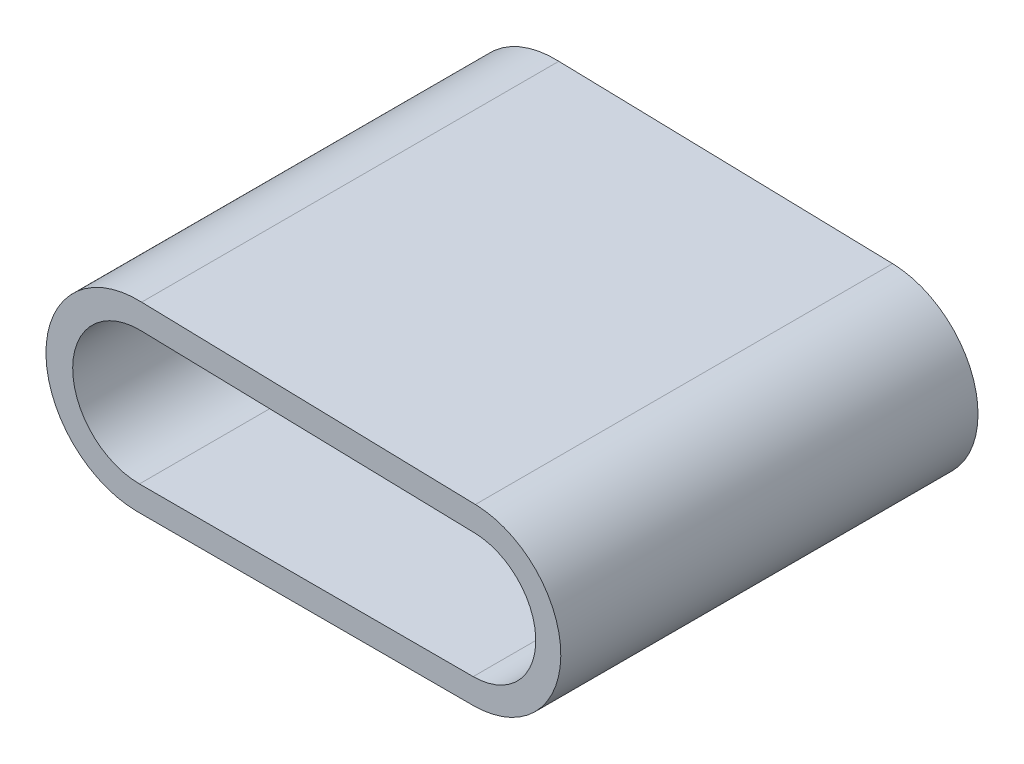
from build123d import *

# Parameters (mm, degrees)
SKETCH1_W           = 31.75
SKETCH1_H           = 31.75
BOSS_EXTRUDE1_DEPTH = 2.54
BOSS_EXTRUDE2_DEPTH = 31.75
CUT_EXTRUDE1_DEPTH  = 42.009788671


with BuildPart() as part:
    # Sketch1 → Boss-Extrude1 (new body)
    with BuildSketch(Plane(origin=(0, 0, 0), x_dir=(1, 0, 0), z_dir=(0, 1, 0))):
        Rectangle(SKETCH1_W, SKETCH1_H)
    extrude(amount=BOSS_EXTRUDE1_DEPTH)

    # Sketch2 → Boss-Extrude2 (add, through all)
    with BuildSketch(Plane.XY.offset(15.875)):
        with BuildLine():
            ThreePointArc((10.757698592, 11.42851198), (15.254678119, 7.83956856), (13.014608296, 2.54))
            Line((13.014608296, 2.54), (15.875, 2.54))
            ThreePointArc((15.875, 2.54), (16.673544098, 9.502227526), (10.805315687, 13.332916772))
            Line((10.805315687, 13.332916772), (-14.594684313, 13.9680098))
            ThreePointArc((-14.594684313, 13.9680098), (-21.844382089, 7.62745208), (-15.875, 0.069193847))
            Line((-15.875, 0.069193847), (-15.875, 2.028572795))
            ThreePointArc((-15.875, 2.028572795), (-19.803445065, 7.604369283), (-14.642301408, 12.063605008))
            Line((-14.642301408, 12.063605008), (10.757698592, 11.42851198))
        make_face()
        with BuildLine():
            ThreePointArc((13.014608296, 2.54), (11.868328068, 2.066487883), (10.638655855, 1.905))
            Line((10.638655855, 1.905), (-14.761344145, 1.905))
            ThreePointArc((-14.761344145, 1.905), (-15.321589537, 1.93598771), (-15.875, 2.028572795))
            Line((-15.875, 2.028572795), (-15.875, 0.069193847))
            ThreePointArc((-15.875, 0.069193847), (-15.444137647, 0.021191286), (-15.011127782, 0))
            Line((-15.011127782, 0), (-14.761344145, 0))
            Line((-14.761344145, 0), (10.638655855, 0))
            ThreePointArc((10.638655855, 0), (13.548591422, 0.668514148), (15.875, 2.54))
            Line((15.875, 2.54), (13.014608296, 2.54))
        make_face()
    extrude(amount=-BOSS_EXTRUDE2_DEPTH)

    # Sketch3 → Cut-Extrude1 (cut, through all)
    with BuildSketch(Plane.XY.offset(15.875)):
        with BuildLine():
            Line((13.014608296, 2.54), (-15.875, 2.54))
            Line((-15.875, 2.54), (-15.875, 2.028572795))
            ThreePointArc((-15.875, 2.028572795), (-15.321589537, 1.93598771), (-14.761344145, 1.905))
            Line((-14.761344145, 1.905), (10.638655855, 1.905))
            ThreePointArc((10.638655855, 1.905), (11.868328068, 2.066487883), (13.014608296, 2.54))
        make_face()
        with BuildLine():
            Line((15.875, 0), (15.875, 2.54))
            ThreePointArc((15.875, 2.54), (13.548591422, 0.668514148), (10.638655855, 0))
            Line((10.638655855, 0), (15.875, 0))
        make_face()
        with BuildLine():
            Line((-15.875, 0), (-15.011127782, 0))
            ThreePointArc((-15.011127782, 0), (-15.444137647, 0.021191286), (-15.875, 0.069193847))
            Line((-15.875, 0.069193847), (-15.875, 0))
        make_face()
    extrude(amount=-CUT_EXTRUDE1_DEPTH, mode=Mode.SUBTRACT)


solid = part.part
